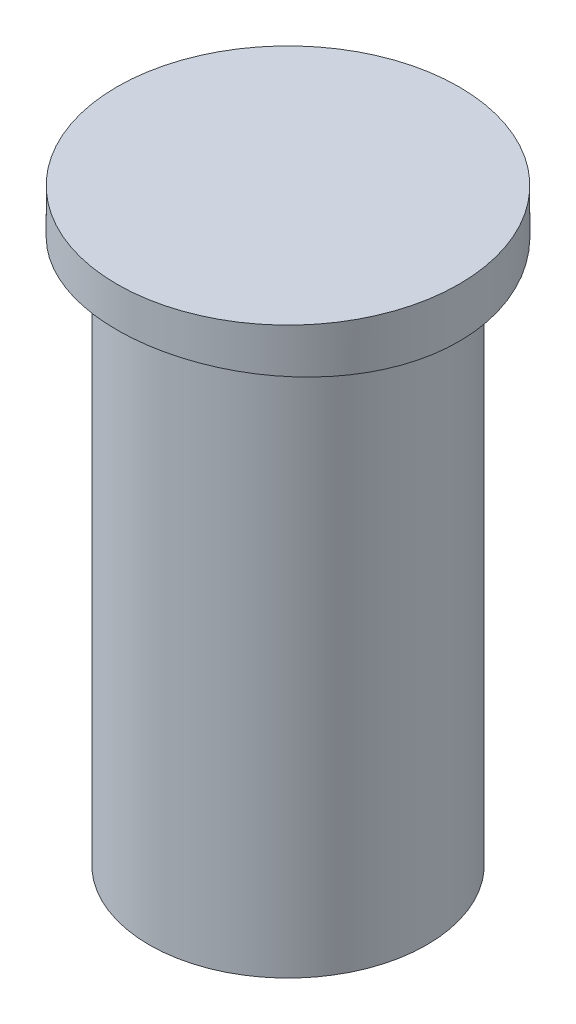
from build123d import *

# Parameters (mm, degrees)
SKETCH1_R               = 6.1849
BOSS_EXTRUDE1_DEPTH     = 23.9776
SKETCH2_R               = 7.62
BOSS_EXTRUDE2_DEPTH     = 2.2352
SKETCH4_R               = 7.62
SKETCH4_R_2             = 6.1849
CUT_EXTRUDE2_DEPTH      = 24.9776
CUT_EXTRUDE2_DEPTH_BACK = 0.0254
CUT_EXTRUDE3_DEPTH      = 8.62
CUT_EXTRUDE3_DEPTH_BACK = 8.62


with BuildPart() as part:
    # Sketch1 → Boss-Extrude1 (new body)
    with BuildSketch(Plane(origin=(0, 0, 0), x_dir=(1, 0, 0), z_dir=(0, 1, 0))):
        Circle(SKETCH1_R)
    extrude(amount=BOSS_EXTRUDE1_DEPTH)

    # Sketch2 → Boss-Extrude2 (add)
    with BuildSketch(Plane(origin=(0, 23.9776, 0), x_dir=(1, 0, 0), z_dir=(0, 1, 0))):
        Circle(SKETCH2_R)
    extrude(amount=BOSS_EXTRUDE2_DEPTH)

    # Sketch4 → Cut-Extrude2 (cut, two sides)
    with BuildSketch(Plane.XZ.offset(-23.9776)) as cut_extrude2_sk:
        Circle(SKETCH4_R)
        Circle(SKETCH4_R_2, mode=Mode.SUBTRACT)
    extrude(amount=CUT_EXTRUDE2_DEPTH, mode=Mode.SUBTRACT)
    extrude(cut_extrude2_sk.sketch, amount=-CUT_EXTRUDE2_DEPTH_BACK, mode=Mode.SUBTRACT)

    # Sketch8 → Cut-Extrude3 (cut, two sides)
    with BuildSketch(Plane.XY) as cut_extrude3_sk:
        with BuildLine():
            Line((-7.62, 24.003), (7.62, 24.003))
            ThreePointArc((7.62, 24.003), (0, 24.448400055), (-7.62, 24.003))
        make_face()
    extrude(amount=CUT_EXTRUDE3_DEPTH, mode=Mode.SUBTRACT)
    extrude(cut_extrude3_sk.sketch, amount=-CUT_EXTRUDE3_DEPTH_BACK, mode=Mode.SUBTRACT)


solid = part.part
